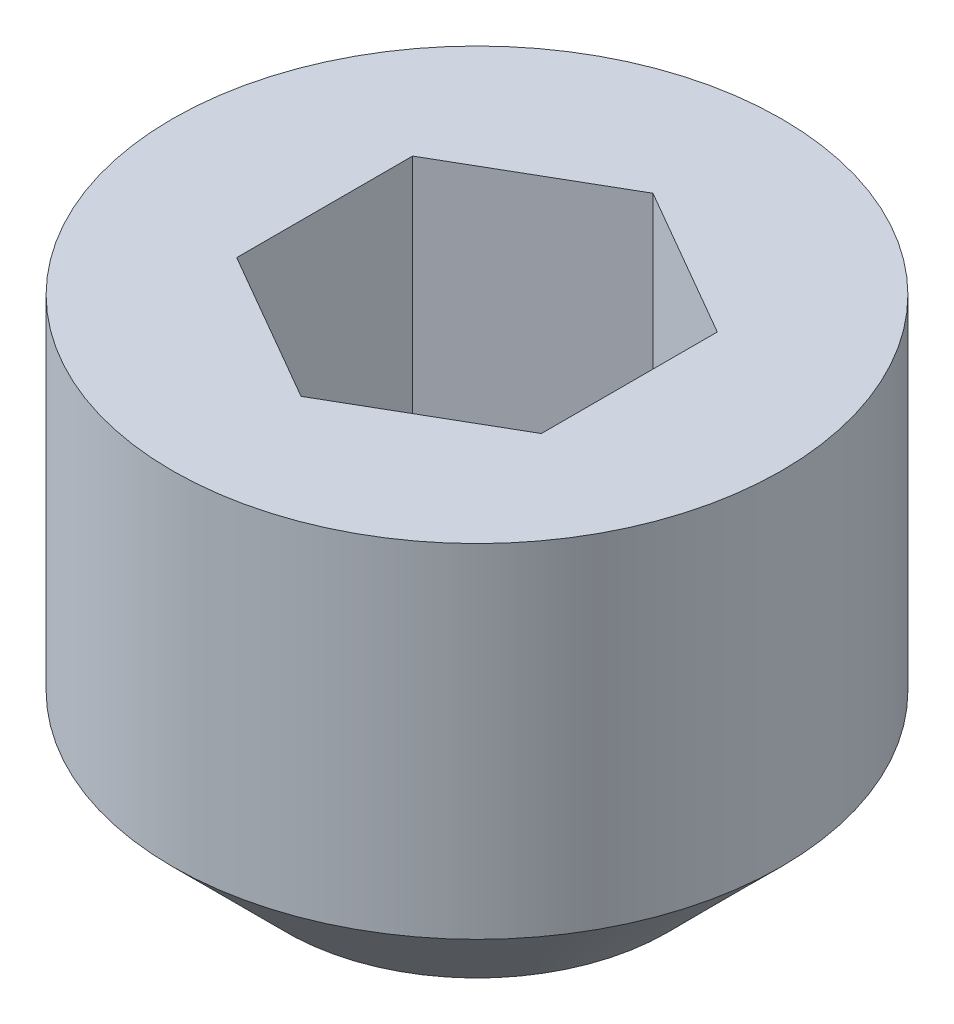
from build123d import *

# Parameters (mm, degrees)
SKETCH1_W          = 2
SKETCH1_H          = 3
CUT_EXTRUDE1_DEPTH = 1.5


with BuildPart() as part:
    # Sketch1 → Revolve1 (revolve)
    with BuildSketch(Plane.XY):
        with Locations((1, 1.5)):
            Rectangle(SKETCH1_W, SKETCH1_H)
    revolve(axis=Axis((0, 3, 0), (0, -1, 0)))

    # Sketch2 → Cut-Revolve1 (revolve, cut)
    with BuildSketch(Plane.XY):
        Polygon((0, 3), (1, 3), (1, 1.5), (0, 0.922649731), align=None)
    revolve(axis=Axis((0, 3, 0), (0, -1, 0)), mode=Mode.SUBTRACT)

    # Sketch3 → Cut-Extrude1 (cut)
    with BuildSketch(Plane(origin=(0, 3, 0), x_dir=(1, 0, 0), z_dir=(0, 1, 0))):
        Polygon((0, 1.154700538), (-1, 0.577350269), (-1, -0.577350269), (0, -1.154700538), (1, -0.577350269), (1, 0.577350269), align=None)
    extrude(amount=-CUT_EXTRUDE1_DEPTH, mode=Mode.SUBTRACT)

    # Sketch4 → Cut-Revolve2 (revolve, cut)
    with BuildSketch(Plane.XY):
        Polygon((2, 0.75), (2, 0), (1.25, 0), align=None)
    revolve(axis=Axis((0, 3, 0), (0, -1, 0)), mode=Mode.SUBTRACT)


solid = part.part
